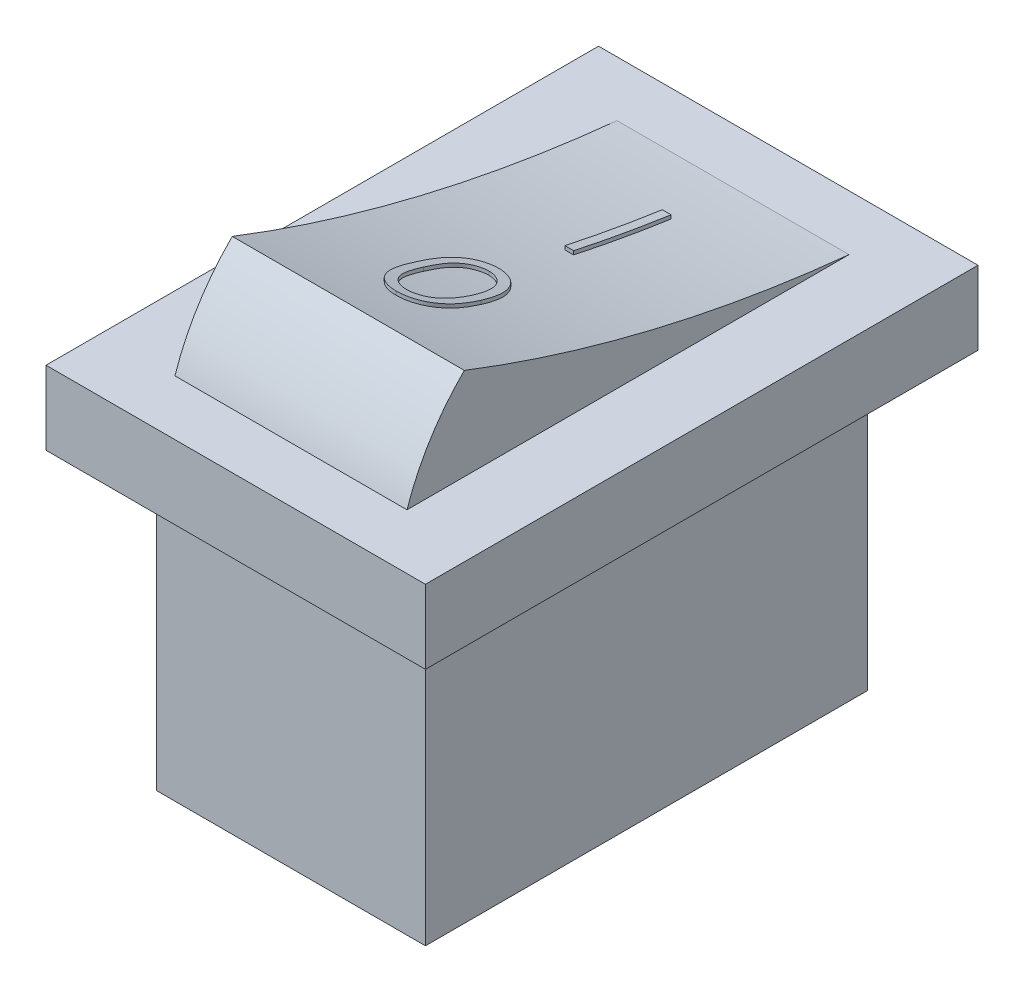
from build123d import *

# Parameters (mm, degrees)
SKETCH1_W                = 10.3
SKETCH1_H                = 15
BOSS_EXTRUDE1_DEPTH      = 2
BOSS_EXTRUDE2_DEPTH      = 3.15
SKETCH3_W                = 7.3
SKETCH3_H                = 12
BOSS_EXTRUDE3_DEPTH      = 8
BOSS_EXTRUDE4_REACH      = 22.811
BOSS_EXTRUDE4_END_RADIUS = 39.69103093
SKETCH4_W                = 0.237446582
SKETCH4_H                = 2.645833333


with BuildPart() as part:
    # Sketch1 → Boss-Extrude1 (new body)
    with BuildSketch(Plane(origin=(0, 0, 0), x_dir=(1, 0, 0), z_dir=(0, 1, 0))):
        with Locations((5.15, 7.5)):
            Rectangle(SKETCH1_W, SKETCH1_H)
    extrude(amount=BOSS_EXTRUDE1_DEPTH)

    # Sketch2 → Boss-Extrude2 (add, symmetric)
    with BuildSketch(Plane(origin=(5.15, 0, 0), x_dir=(0, 0, -1), z_dir=(1, 0, 0))):
        with BuildLine():
            Line((13.5, 2), (1.5, 2))
            ThreePointArc((1.5, 2), (2.130429102, 3.341812139), (3.055902791, 4.5))
            ThreePointArc((3.055902791, 4.5), (8.193008298, 2.895138414), (13.5, 2))
        make_face()
    extrude(amount=BOSS_EXTRUDE2_DEPTH, both=True)

    # Sketch3 → Boss-Extrude3 (add)
    with BuildSketch(Plane.XZ):
        with Locations((5.15, -7.5)):
            Rectangle(SKETCH3_W, SKETCH3_H)
    extrude(amount=BOSS_EXTRUDE3_DEPTH)

    # Boss-Extrude4: up to this cylinder (the profile starts outside it)
    boss_extrude4_end = Plane(origin=(4.78378, 41.59570755, -17.432813416), z_dir=(-1, 0, 0)) * Cylinder(BOSS_EXTRUDE4_END_RADIUS, 126.736501859, mode=Mode.PRIVATE)
    # Sketch4 → Boss-Extrude4 (add, up to the surface)
    with BuildSketch(Plane(origin=(0, 2.1, 0), x_dir=(1, 0, 0), z_dir=(0, 1, 0)), mode=Mode.PRIVATE) as boss_extrude4_sk1:
        with Locations((5.15, 10.377361229)):
            Rectangle(SKETCH4_W, SKETCH4_H)
    boss_extrude4_tool1 = extrude(boss_extrude4_sk1.sketch, amount=BOSS_EXTRUDE4_REACH, mode=Mode.PRIVATE) - boss_extrude4_end
    add(boss_extrude4_tool1.solids().sort_by_distance((5.15, 2.1, -10.377361))[0])
    # Sketch4 → Boss-Extrude4 (add, up to the surface)
    with BuildSketch(Plane(origin=(0, 2.1, 0), x_dir=(1, 0, 0), z_dir=(0, 1, 0)), mode=Mode.PRIVATE) as boss_extrude4_sk2:
        with BuildLine():
            add(Edge.make_bspline(
                [(4.234134615, 5.775901681), (4.234382581, 5.818308635), (4.234864259, 5.900684754), (4.240222768, 6.020718382), (4.249124366, 6.133325267), (4.261323451, 6.238510799), (4.276168829, 6.336302133), (4.295986489, 6.426437932), (4.318523548, 6.509335372), (4.344643552, 6.585264778), (4.374116464, 6.655249113), (4.406194744, 6.72058245), (4.442151464, 6.781165934), (4.47993163, 6.837966526), (4.521064565, 6.890054438), (4.564379722, 6.93816526), (4.611567688, 6.981187078), (4.661024367, 7.020380413), (4.713197528, 7.05473805), (4.766600019, 7.085000894), (4.821599415, 7.110854365), (4.878345874, 7.131182254), (4.936329356, 7.147972596), (4.995752555, 7.159454717), (5.056713586, 7.166679285), (5.097861159, 7.167369974), (5.118729133, 7.167720257)],
                knots=[0, 0, 0, 0, 1.646270934, 3.197905019, 4.663502075, 6.030701355, 7.308322542, 8.50163776, 9.611534131, 10.641858119, 11.616356847, 12.558055219, 13.465016945, 14.349605745, 15.204443733, 16.039544428, 16.859896111, 17.680448484, 18.487036065, 19.28249412, 20.06191084, 20.843045899, 21.620316918, 22.403196591, 23.190181807, 24, 24, 24, 24], degree=3))
            add(Edge.make_bspline(
                [(5.118729133, 7.167720257), (5.13977143, 7.167351492), (5.181617936, 7.166618135), (5.243485363, 7.159569678), (5.303923515, 7.147874246), (5.362674727, 7.131303033), (5.420221592, 7.110744396), (5.476113995, 7.084976159), (5.53069911, 7.054980825), (5.583109506, 7.019735394), (5.633920555, 6.980439268), (5.681884194, 6.936017489), (5.727004788, 6.886918594), (5.76984862, 6.833667899), (5.809200173, 6.775244055), (5.846675327, 6.71266321), (5.880218473, 6.644830949), (5.912523853, 6.572879048), (5.940408658, 6.494816639), (5.965556355, 6.411083755), (5.985875576, 6.320691364), (6.0028008, 6.224113726), (6.015912715, 6.120996164), (6.025462391, 6.011559723), (6.030506925, 5.895732404), (6.031456932, 5.816540459), (6.031944444, 5.775901681)],
                knots=[0, 0, 0, 0, 0.810914788, 1.612654377, 2.396697861, 3.181598691, 3.963628158, 4.749916497, 5.551656086, 6.361998678, 7.18212741, 8.025565596, 8.878627764, 9.750805457, 10.657531673, 11.591944965, 12.560506719, 13.57287815, 14.630710178, 15.753379473, 16.941251878, 18.199788006, 19.531962791, 20.947069417, 22.433333509, 24, 24, 24, 24], degree=3))
            add(Edge.make_bspline(
                [(6.031944444, 5.775901681), (6.031451878, 5.735440155), (6.030492131, 5.656602523), (6.025518942, 5.541296369), (6.015722834, 5.432440705), (6.003468855, 5.329774462), (5.986496996, 5.233724953), (5.965628805, 5.143959804), (5.94245862, 5.060091369), (5.913857317, 4.98280672), (5.882552792, 4.911027739), (5.848493209, 4.843999597), (5.81200352, 4.78112984), (5.772248933, 4.722921698), (5.729875221, 4.668962832), (5.683975464, 4.620205701), (5.635843534, 4.575475491), (5.584882958, 4.535673368), (5.531655178, 4.50083545), (5.477257542, 4.469679741), (5.420724866, 4.444557406), (5.363338288, 4.422986274), (5.304276964, 4.406506171), (5.243614514, 4.395111054), (5.181659502, 4.38711924), (5.139778557, 4.386509579), (5.118729133, 4.386203163)],
                knots=[0, 0, 0, 0, 1.561518951, 3.042555995, 4.452378317, 5.7783523, 7.031515105, 8.214008947, 9.334062868, 10.386615937, 11.391082383, 12.354592575, 13.286541444, 14.194233754, 15.072674879, 15.931287219, 16.775624067, 17.606195743, 18.42308326, 19.229000347, 20.022332153, 20.807536673, 21.593273796, 22.3848459, 23.188221202, 24, 24, 24, 24], degree=3))
            add(Edge.make_bspline(
                [(5.118729133, 4.386203163), (5.097861738, 4.386555706), (5.056715306, 4.387250851), (4.995745913, 4.394442779), (4.936568114, 4.406005451), (4.878889889, 4.422195384), (4.822415321, 4.442012552), (4.767913962, 4.46783111), (4.71477982, 4.497565793), (4.663154655, 4.531428999), (4.614008557, 4.570225747), (4.567064969, 4.613136846), (4.523503198, 4.661233116), (4.482958376, 4.713755117), (4.444424393, 4.770219651), (4.408978259, 4.831397648), (4.376191959, 4.897046526), (4.346223368, 4.967590423), (4.319652652, 5.044058731), (4.296182063, 5.127326265), (4.277650527, 5.218127966), (4.261788412, 5.315734547), (4.248994385, 5.420565435), (4.240259865, 5.532677541), (4.234861371, 5.652001003), (4.234381288, 5.733847796), (4.234134615, 5.775901681)],
                knots=[0, 0, 0, 0, 0.810891512, 1.598919785, 2.382837074, 3.152667961, 3.926044502, 4.706494248, 5.493654104, 6.291793342, 7.103789334, 7.925228297, 8.761435821, 9.622817696, 10.50288917, 11.416980706, 12.369136599, 13.353924996, 14.394355917, 15.514179734, 16.714354668, 17.994756427, 19.357759367, 20.818452758, 22.365282078, 24, 24, 24, 24], degree=3))
        make_face()
        with BuildLine():
            add(Edge.make_bspline(
                [(4.471581197, 5.77696171), (4.471671493, 5.74162192), (4.47184674, 5.673034327), (4.47642494, 5.5733671), (4.482661722, 5.480407387), (4.490706036, 5.394037154), (4.502652313, 5.314548752), (4.516037801, 5.241395479), (4.532327131, 5.174964473), (4.55160015, 5.114799878), (4.573552324, 5.059880641), (4.597520448, 5.008777342), (4.623268732, 4.960886295), (4.652084995, 4.916637674), (4.683468406, 4.875887181), (4.716710096, 4.837913552), (4.75305068, 4.804049167), (4.803324343, 4.763434223), (4.869694297, 4.721464402), (4.953318093, 4.68491706), (5.039246029, 4.66194937), (5.0975687, 4.659028554), (5.126679354, 4.657570685)],
                knots=[0, 0, 0, 0, 1.459021318, 2.831673884, 4.118529203, 5.306027144, 6.411944654, 7.436330062, 8.375795394, 9.233974572, 10.042671642, 10.816086306, 11.563610507, 12.285937304, 12.993564865, 13.685989202, 14.367179055, 15.041617293, 16.353048772, 17.594441528, 18.799311195, 20, 20, 20, 20], degree=3))
            add(Edge.make_bspline(
                [(5.126679354, 4.657570685), (5.155978308, 4.658778531), (5.214515725, 4.661191729), (5.300039487, 4.684474108), (5.383065941, 4.719602867), (5.448132229, 4.761140565), (5.497633914, 4.80069829), (5.533100924, 4.83442484), (5.565653782, 4.872189097), (5.596528446, 4.912934398), (5.624845723, 4.957439192), (5.650595833, 5.005489472), (5.674093364, 5.057218672), (5.687480559, 5.09333032), (5.694325087, 5.111793274)],
                knots=[0, 0, 0, 0, 1.353760809, 2.704726607, 4.075137775, 5.516104923, 6.260822281, 7.007110065, 7.778089737, 8.566572457, 9.372053459, 10.217411131, 11.088608312, 12, 12, 12, 12], degree=3))
            add(Edge.make_bspline(
                [(5.694325087, 5.111793274), (5.702301721, 5.13540147), (5.718497709, 5.183336232), (5.739370895, 5.257694469), (5.755809381, 5.335710844), (5.770598354, 5.416919117), (5.780692629, 5.501918177), (5.788817464, 5.590445027), (5.793603162, 5.682566413), (5.794196396, 5.745155484), (5.794497863, 5.77696171)],
                knots=[0, 0, 0, 0, 0.884706709, 1.796334032, 2.740027952, 3.714592787, 4.726048262, 5.777819803, 6.87074269, 8, 8, 8, 8], degree=3))
            add(Edge.make_bspline(
                [(5.794497863, 5.77696171), (5.794081946, 5.808762792), (5.793268324, 5.870972506), (5.790158345, 5.962078511), (5.782127429, 6.048610688), (5.773207857, 6.130941819), (5.760056386, 6.208616155), (5.745876377, 6.282283945), (5.726825461, 6.351032541), (5.706475393, 6.415938296), (5.683184201, 6.476263791), (5.657545521, 6.532290284), (5.630163596, 6.584288261), (5.600422736, 6.632115056), (5.568675999, 6.675984895), (5.534085471, 6.71501819), (5.498023237, 6.750424707), (5.447512626, 6.790839864), (5.381386228, 6.83204811), (5.299104102, 6.869971035), (5.213476889, 6.891748733), (5.155591004, 6.894819175), (5.126679354, 6.896352736)],
                knots=[0, 0, 0, 0, 1.31362396, 2.569729283, 3.763502607, 4.902122613, 5.988968491, 7.01645872, 7.998833611, 8.933434873, 9.825090667, 10.667526885, 11.477055099, 12.250526234, 12.991942729, 13.710640831, 14.402115721, 15.076753259, 16.378508321, 17.609869233, 18.806226677, 20, 20, 20, 20], degree=3))
            add(Edge.make_bspline(
                [(5.126679354, 6.896352736), (5.097415989, 6.894817059), (5.03883595, 6.891742907), (4.952318746, 6.870052174), (4.86938748, 6.832244753), (4.803435946, 6.790703377), (4.752890107, 6.751138105), (4.717297833, 6.716828107), (4.683925429, 6.679297903), (4.653182584, 6.638172646), (4.6243889, 6.593975613), (4.59794492, 6.546359106), (4.57411932, 6.495081825), (4.552132796, 6.440187257), (4.532800986, 6.380027853), (4.516854954, 6.313678673), (4.50212367, 6.240758076), (4.491695103, 6.160839163), (4.482424288, 6.074447297), (4.476466364, 5.981255515), (4.471831425, 5.881421132), (4.471666277, 5.812478911), (4.471581197, 5.77696171)],
                knots=[0, 0, 0, 0, 1.207732386, 2.417664972, 3.655092373, 4.956220595, 5.625982001, 6.301752483, 6.994047911, 7.697131622, 8.419323945, 9.170223765, 9.943494443, 10.752040957, 11.610060368, 12.549350801, 13.567764191, 14.679664412, 15.874934091, 17.154273443, 18.533957287, 20, 20, 20, 20], degree=3))
        make_face(mode=Mode.SUBTRACT)
    boss_extrude4_tool2 = extrude(boss_extrude4_sk2.sketch, amount=BOSS_EXTRUDE4_REACH, mode=Mode.PRIVATE) - boss_extrude4_end
    add(boss_extrude4_tool2.solids().sort_by_distance((4.41756, 2.1, -6.668108))[0])


solid = part.part
